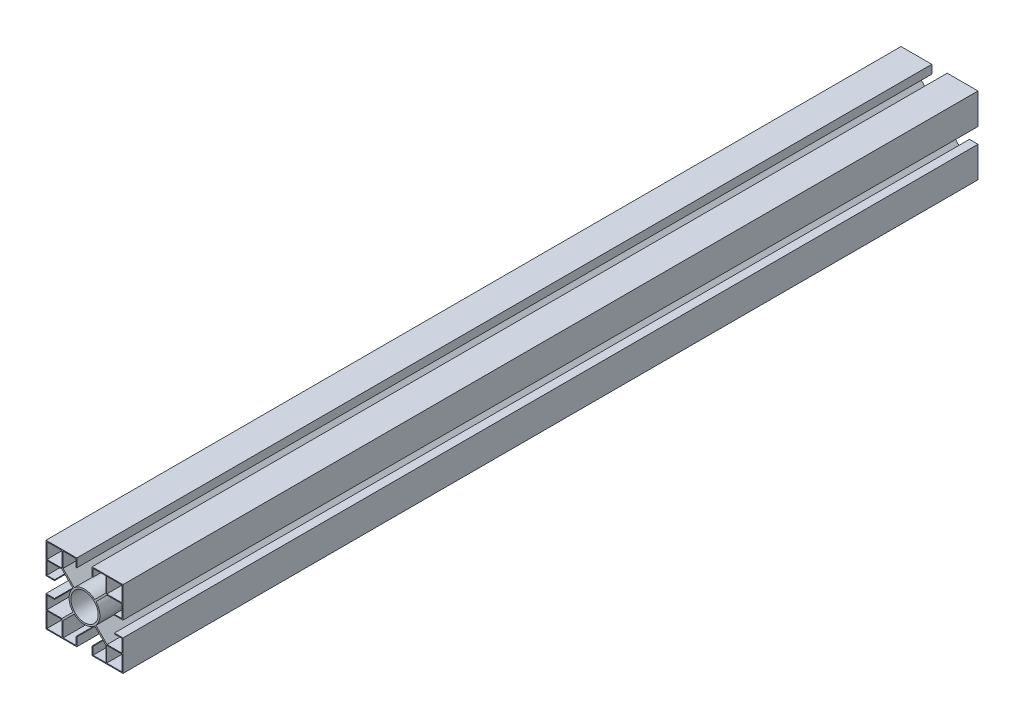
from build123d import *

# Parameters (mm, degrees)
ESBO_O1_W                = 9
ESBO_O1_H                = 9
ESBO_O1_R                = 8
RESSALTO_EXTRUS_O4_DEPTH = 500


with BuildPart() as part:
    # Esboço1 → Ressalto-extrusão4 (new body)
    with BuildSketch(Plane.XY):
        with BuildLine():
            Line((-4.5, 22.5), (-22.5, 22.5))
            Line((-22.5, 22.5), (-22.5, 4.5))
            Line((-22.5, 4.5), (-17.5, 4.5))
            Line((-17.5, 4.5), (-17.5, 5))
            Line((-17.5, 5), (-22, 5))
            Line((-22, 5), (-22, 12.5))
            Line((-22, 12.5), (-13.207106781, 12.5))
            Line((-13.207106781, 12.5), (-6.707685904, 6.000579123))
            ThreePointArc((-6.707685904, 6.000579123), (-9, 0), (-6.707685904, -6.000579123))
            Line((-6.707685904, -6.000579123), (-13.207106781, -12.5))
            Line((-13.207106781, -12.5), (-22, -12.5))
            Line((-22, -12.5), (-22, -5))
            Line((-22, -5), (-17.5, -5))
            Line((-17.5, -5), (-17.5, -4.5))
            Line((-17.5, -4.5), (-22.5, -4.5))
            Line((-22.5, -4.5), (-22.5, -22.5))
            Line((-22.5, -22.5), (-4.5, -22.5))
            Line((-4.5, -22.5), (-4.5, -17.5))
            Line((-4.5, -17.5), (-5, -17.5))
            Line((-5, -17.5), (-5, -22))
            Line((-5, -22), (-12.5, -22))
            Line((-12.5, -22), (-12.5, -13.207106781))
            Line((-12.5, -13.207106781), (-6.000579123, -6.707685904))
            ThreePointArc((-6.000579123, -6.707685904), (0, -9), (6.000579123, -6.707685904))
            Line((6.000579123, -6.707685904), (12.5, -13.207106781))
            Line((12.5, -13.207106781), (12.5, -22))
            Line((12.5, -22), (5, -22))
            Line((5, -22), (5, -17.5))
            Line((5, -17.5), (4.5, -17.5))
            Line((4.5, -17.5), (4.5, -22.5))
            Line((4.5, -22.5), (22.5, -22.5))
            Line((22.5, -22.5), (22.5, -4.5))
            Line((22.5, -4.5), (17.5, -4.5))
            Line((17.5, -4.5), (17.5, -5))
            Line((17.5, -5), (22, -5))
            Line((22, -5), (22, -12.5))
            Line((22, -12.5), (13.207106781, -12.5))
            Line((13.207106781, -12.5), (6.707685904, -6.000579123))
            ThreePointArc((6.707685904, -6.000579123), (9, 0), (6.707685904, 6.000579123))
            Line((6.707685904, 6.000579123), (13.207106781, 12.5))
            Line((13.207106781, 12.5), (22, 12.5))
            Line((22, 12.5), (22, 5))
            Line((22, 5), (17.5, 5))
            Line((17.5, 5), (17.5, 4.5))
            Line((17.5, 4.5), (22.5, 4.5))
            Line((22.5, 4.5), (22.5, 22.5))
            Line((22.5, 22.5), (4.5, 22.5))
            Line((4.5, 22.5), (4.5, 17.5))
            Line((4.5, 17.5), (5, 17.5))
            Line((5, 17.5), (5, 22))
            Line((5, 22), (12.5, 22))
            Line((12.5, 22), (12.5, 13.207106781))
            Line((12.5, 13.207106781), (6.000579123, 6.707685904))
            ThreePointArc((6.000579123, 6.707685904), (0, 9), (-6.000579123, 6.707685904))
            Line((-6.000579123, 6.707685904), (-12.5, 13.207106781))
            Line((-12.5, 13.207106781), (-12.5, 22))
            Line((-12.5, 22), (-5, 22))
            Line((-5, 22), (-5, 17.5))
            Line((-5, 17.5), (-4.5, 17.5))
            Line((-4.5, 17.5), (-4.5, 22.5))
        make_face()
        with Locations((17.5, 17.5)):
            Rectangle(ESBO_O1_W, ESBO_O1_H, mode=Mode.SUBTRACT)
        with Locations((-17.5, -17.5)):
            Rectangle(ESBO_O1_W, ESBO_O1_H, mode=Mode.SUBTRACT)
        with Locations((17.5, -17.5)):
            Rectangle(ESBO_O1_W, ESBO_O1_H, mode=Mode.SUBTRACT)
        with Locations((-17.5, 17.5)):
            Rectangle(ESBO_O1_W, ESBO_O1_H, mode=Mode.SUBTRACT)
        Circle(ESBO_O1_R, mode=Mode.SUBTRACT)
    extrude(amount=RESSALTO_EXTRUS_O4_DEPTH)


solid = part.part
